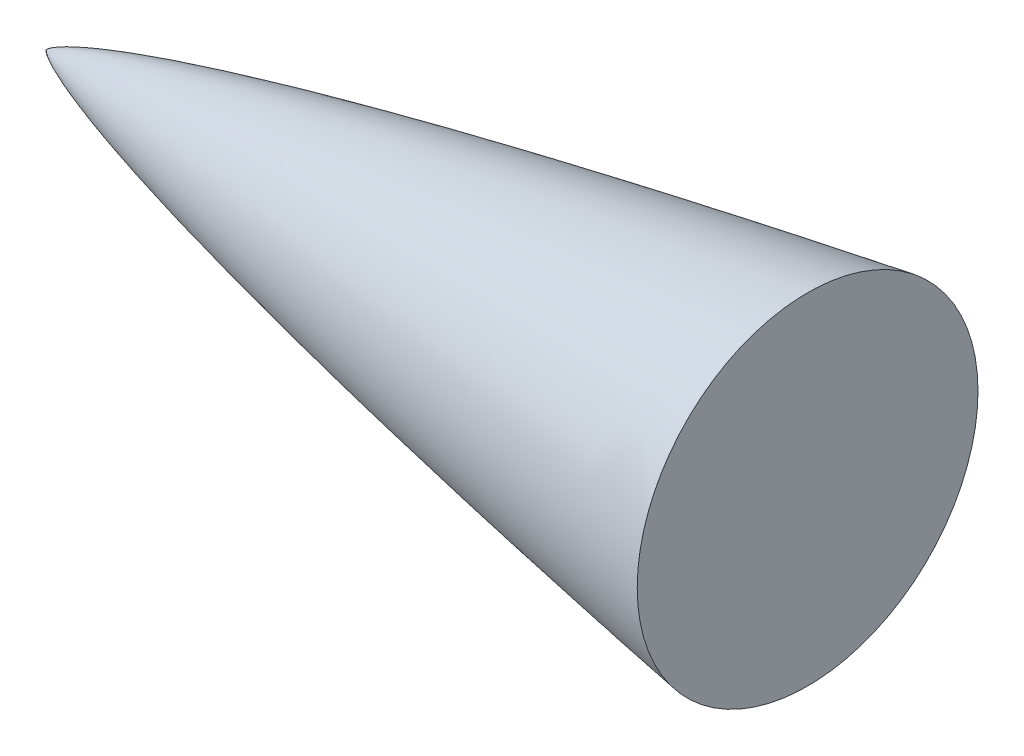
from build123d import *

# Parameters (mm, degrees)
SKETCH2_W          = 635
SKETCH2_H          = 177.8
CUT_EXTRUDE1_DEPTH = 337.058


with BuildPart() as part:
    # Sketch1 → Revolve1 (revolve)
    with BuildSketch(Plane(origin=(0, 0, 0), x_dir=(1, 0, 0), z_dir=(0, 1, 0))):
        with BuildLine():
            Line((0, 0), (635, 0))
            Line((635, 0), (635, 65.405))
            add(Edge.make_bspline(
                [(0, 0), (0.002192115, 0.006290208), (0.007522969, 0.018367599), (0.022271668, 0.040384559), (0.056983677, 0.080426255), (0.109817079, 0.130424863), (0.181602896, 0.188889433), (0.283649616, 0.263361483), (0.406270252, 0.344359984), (0.550210431, 0.431764809), (0.715531562, 0.525146598), (0.956716029, 0.653660621), (1.331811412, 0.839140677), (1.970276917, 1.127501619), (3.115826799, 1.592189007), (5.163395415, 2.328403475), (8.933180628, 3.515485788), (16.022028295, 5.446250201), (28.261741777, 8.304992794), (49.178793555, 12.513579304), (77.957328785, 17.487301978), (112.870807325, 22.806136935), (151.857530338, 28.124197322), (190.903568879, 32.982699255), (229.995170685, 37.459233955), (269.123174714, 41.603760556), (308.282068326, 45.445401222), (347.467762428, 49.002567332), (386.677550901, 52.283613526), (425.909385737, 55.28952525), (465.161890457, 58.012752885), (504.434100625, 60.436186371), (538.814064528, 62.266460598), (568.294487813, 63.592457812), (591.989866174, 64.466582586), (607.876612197, 64.942044427), (620.867800744, 65.238425835), (628.943051519, 65.360798765), (632.980968041, 65.399904908), (635, 65.405)],
                knots=[0, 0, 0, 0, 0, 4.1322e-05, 8.2644e-05, 0.000165287, 0.000330575, 0.000495862, 0.00066115, 0.00095525, 0.001249349, 0.001548926, 0.001848503, 0.002664392, 0.003865965, 0.00592961, 0.009578293, 0.016270012, 0.028578882, 0.05187103, 0.088176104, 0.149698422, 0.211220737, 0.272743055, 0.334265373, 0.395787692, 0.457310011, 0.518832329, 0.580354648, 0.641876966, 0.703399285, 0.764921604, 0.826443922, 0.887966241, 0.9187274, 0.94948856, 0.97474428, 0.98737214, 1, 1, 1, 1, 1], degree=4))
        make_face()
    revolve(axis=Axis((0, 0, 0), (1, 0, 0)))

    # Sketch2 → Cut-Extrude1 (cut)
    with BuildSketch(Plane.XY.offset(-203.2)):
        with Locations((393.7, 0)):
            Rectangle(SKETCH2_W, SKETCH2_H)
    extrude(amount=CUT_EXTRUDE1_DEPTH, mode=Mode.SUBTRACT)


solid = part.part
